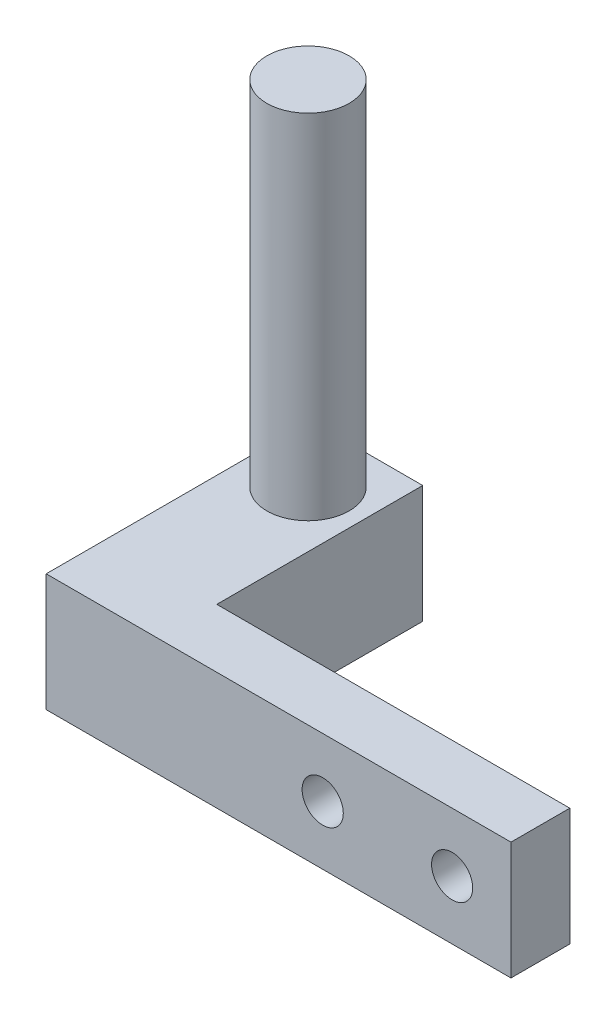
from build123d import *

# Parameters (mm, degrees)
SKETCH1_W           = 12.5
SKETCH1_H           = 10
BOSS_EXTRUDE1_DEPTH = 10
SKETCH2_W           = 10
SKETCH2_H           = 10
BOSS_EXTRUDE2_DEPTH = 5
SKETCH3_R           = 3.5
BOSS_EXTRUDE3_DEPTH = 30
SKETCH4_W           = 4
SKETCH4_H           = 10
CUT_EXTRUDE1_DEPTH  = 11
SKETCH5_W           = 9.5
SKETCH5_H           = 10
BOSS_EXTRUDE4_DEPTH = 12.5
SKETCH6_W           = 5
SKETCH6_H           = 10
BOSS_EXTRUDE5_DEPTH = 30
SKETCH7_R           = 1.75
CUT_EXTRUDE2_DEPTH  = 23.5


with BuildPart() as part:
    # Sketch1 → Boss-Extrude1 (new body)
    with BuildSketch(Plane.XY):
        with Locations((6.25, 5)):
            Rectangle(SKETCH1_W, SKETCH1_H)
    extrude(amount=BOSS_EXTRUDE1_DEPTH)

    # Sketch2 → Boss-Extrude2 (add)
    with BuildSketch(Plane.ZY):
        with Locations((5, 5)):
            Rectangle(SKETCH2_W, SKETCH2_H)
    extrude(amount=BOSS_EXTRUDE2_DEPTH)

    # Sketch3 → Boss-Extrude3 (add)
    with BuildSketch(Plane(origin=(0, 10, 0), x_dir=(1, 0, 0), z_dir=(0, 1, 0))):
        with Locations((3.75, -5)):
            Circle(SKETCH3_R)
    extrude(amount=BOSS_EXTRUDE3_DEPTH)

    # Sketch4 → Cut-Extrude1 (cut, through all)
    with BuildSketch(Plane(origin=(0, 10, 0), x_dir=(1, 0, 0), z_dir=(0, 1, 0))):
        with Locations((10.5, -5)):
            Rectangle(SKETCH4_W, SKETCH4_H)
        with Locations((-3, -5)):
            Rectangle(SKETCH4_W, SKETCH4_H)
    extrude(amount=-CUT_EXTRUDE1_DEPTH, mode=Mode.SUBTRACT)

    # Sketch5 → Boss-Extrude4 (add)
    with BuildSketch(Plane.XY.offset(10)):
        with Locations((3.75, 5)):
            Rectangle(SKETCH5_W, SKETCH5_H)
    extrude(amount=BOSS_EXTRUDE4_DEPTH)

    # Sketch6 → Boss-Extrude5 (add)
    with BuildSketch(Plane(origin=(8.5, 0, 0), x_dir=(0, 0, -1), z_dir=(1, 0, 0))):
        with Locations((-20, 5)):
            Rectangle(SKETCH6_W, SKETCH6_H)
    extrude(amount=BOSS_EXTRUDE5_DEPTH)

    # Sketch7 → Cut-Extrude2 (cut, through all)
    with BuildSketch(Plane.XY.offset(22.5)):
        with Locations((22.5, 5)):
            Circle(SKETCH7_R)
        with Locations((33.5, 5)):
            Circle(SKETCH7_R)
    extrude(amount=-CUT_EXTRUDE2_DEPTH, mode=Mode.SUBTRACT)


solid = part.part
